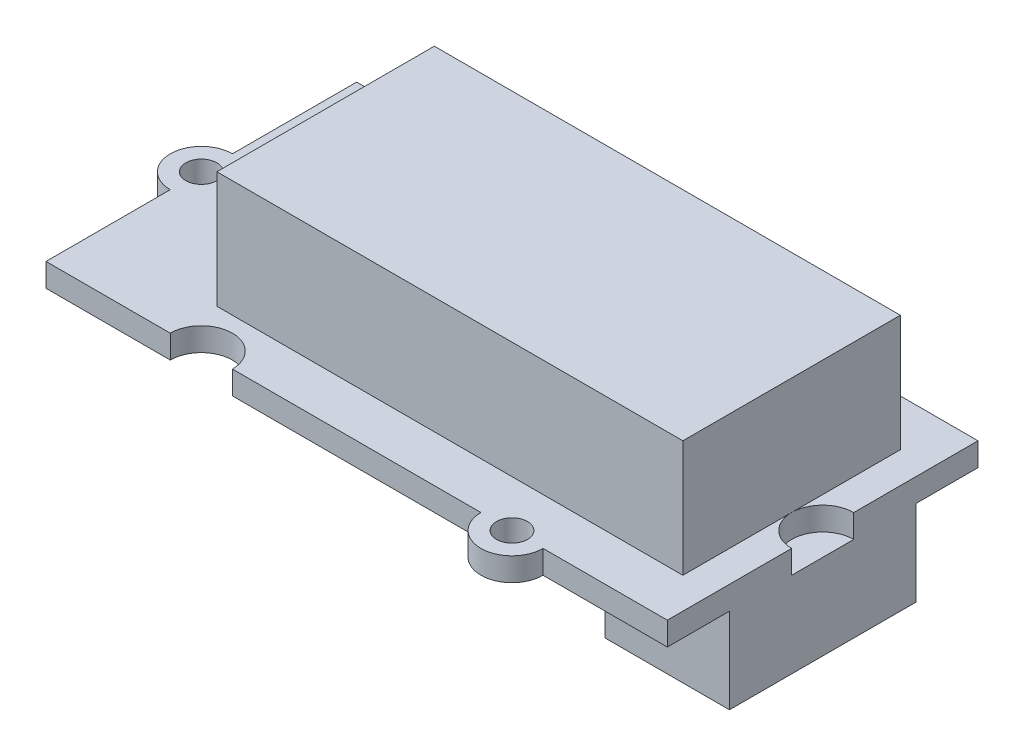
from build123d import *

# Parameters (mm, degrees)
SKETCH_1_R      = 1
EXTRUDE_1_DEPTH = 1.5
SKETCH_2_W      = 30
SKETCH_2_H      = 14
EXTRUDE_2_DEPTH = 7.5
SKETCH_3_W      = 8
SKETCH_3_H      = 12
EXTRUDE_3_DEPTH = 5.5


with BuildPart() as part:
    # Эскиз1 → Бобышка-Вытянуть1 (new body)
    with BuildSketch(Plane(origin=(0, 0, 0), x_dir=(1, 0, 0), z_dir=(0, 1, 0))):
        with BuildLine():
            Line((-20, 10), (-12, 10))
            ThreePointArc((-12, 10), (-10, 8), (-8, 10))
            Line((-8, 10), (8, 10))
            ThreePointArc((8, 10), (10, 12), (12, 10))
            Line((12, 10), (20, 10))
            Line((20, 10), (20, 2))
            ThreePointArc((20, 2), (18, 0), (20, -2))
            Line((20, -2), (20, -10))
            Line((20, -10), (12, -10))
            ThreePointArc((12, -10), (10, -12), (8, -10))
            Line((8, -10), (-8, -10))
            ThreePointArc((-8, -10), (-10, -8), (-12, -10))
            Line((-12, -10), (-20, -10))
            Line((-20, -10), (-20, -2))
            ThreePointArc((-20, -2), (-22, 0), (-20, 2))
            Line((-20, 2), (-20, 10))
        make_face()
        with Locations((-20, 0)):
            Circle(SKETCH_1_R, mode=Mode.SUBTRACT)
        with Locations((10, 10)):
            Circle(SKETCH_1_R, mode=Mode.SUBTRACT)
        with Locations((10, -10)):
            Circle(SKETCH_1_R, mode=Mode.SUBTRACT)
    extrude(amount=EXTRUDE_1_DEPTH)

    # Эскиз2 → Бобышка-Вытянуть2 (add)
    with BuildSketch(Plane(origin=(0, 1.5, 0), x_dir=(1, 0, 0), z_dir=(0, 1, 0))):
        with Locations((3, 0)):
            Rectangle(SKETCH_2_W, SKETCH_2_H)
    extrude(amount=EXTRUDE_2_DEPTH)

    # Эскиз3 → Бобышка-Вытянуть3 (add)
    with BuildSketch(Plane.XZ):
        with Locations((16, 0)):
            Rectangle(SKETCH_3_W, SKETCH_3_H)
    extrude(amount=EXTRUDE_3_DEPTH)


solid = part.part
